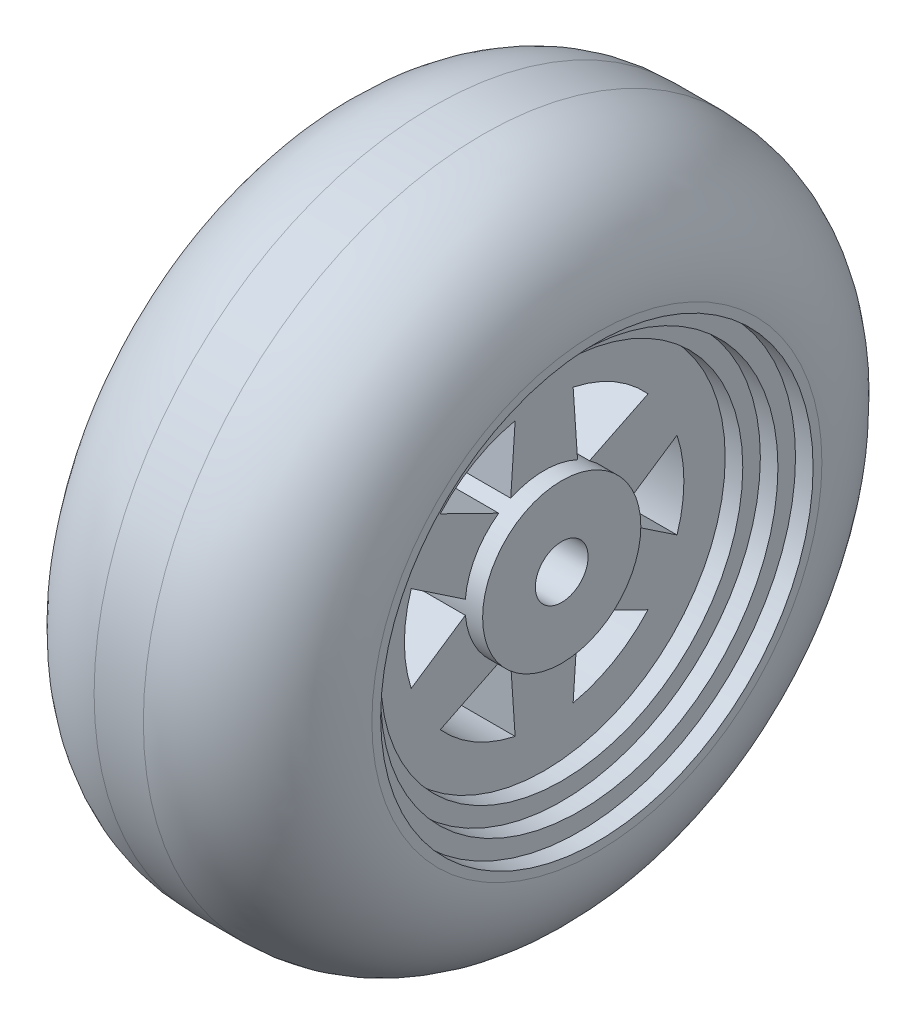
from build123d import *

# Parameters (mm, degrees)
ESQUISSE1_R             = 19.3
EXTRUSION1_DEPTH        = 15.8
ESQUISSE2_R             = 12.3
ENL_V_MAT_EXTRU_1_DEPTH = 1
ESQUISSE3_R             = 11.3
ENL_V_MAT_EXTRU_2_DEPTH = 1
ESQUISSE4_R             = 10.3
ENL_V_MAT_EXTRU_3_DEPTH = 1
ESQUISSE6_R             = 12.3
ENL_V_MAT_EXTRU_4_DEPTH = 1
ESQUISSE7_R             = 4.5
EXTRUSION3_DEPTH        = 5
ESQUISSE8_R             = 4.5
EXTRUSION4_DEPTH        = 1
ESQUISSE9_R             = 1.5
ENL_V_MAT_EXTRU_5_DEPTH = 18.8
CONG_1_R                = 6.5


with BuildPart() as part:
    # Esquisse1 → Extrusion1 (new body)
    with BuildSketch(Plane(origin=(0, 0, 0), x_dir=(0, 0, -1), z_dir=(1, 0, 0))):
        Circle(ESQUISSE1_R)
        with BuildLine():
            Line((1.9, 4.079215611), (1.65, 7.776888838))
            ThreePointArc((1.65, 7.776888838), (3.975, 6.88490196), (5.909983296, 5.317386335))
            Line((5.909983296, 5.317386335), (2.582704347, 3.685056073))
            ThreePointArc((2.582704347, 3.685056073), (2.25, 3.897114317), (1.9, 4.079215611))
        make_face(mode=Mode.SUBTRACT)
        with BuildLine():
            Line((-1.9, 4.079215611), (-1.65, 7.776888838))
            ThreePointArc((-1.65, 7.776888838), (-3.975, 6.88490196), (-5.909983296, 5.317386335))
            Line((-5.909983296, 5.317386335), (-2.582704347, 3.685056073))
            ThreePointArc((-2.582704347, 3.685056073), (-2.25, 3.897114317), (-1.9, 4.079215611))
        make_face(mode=Mode.SUBTRACT)
        with BuildLine():
            Line((4.482704347, 0.394159538), (7.559983296, 2.459502503))
            ThreePointArc((7.559983296, 2.459502503), (7.95, 0), (7.559983296, -2.459502503))
            Line((7.559983296, -2.459502503), (4.482704347, -0.394159538))
            ThreePointArc((4.482704347, -0.394159538), (4.5, 0), (4.482704347, 0.394159538))
        make_face(mode=Mode.SUBTRACT)
        with BuildLine():
            Line((2.582704347, -3.685056073), (5.909983296, -5.317386335))
            ThreePointArc((5.909983296, -5.317386335), (3.975, -6.88490196), (1.65, -7.776888838))
            Line((1.65, -7.776888838), (1.9, -4.079215611))
            ThreePointArc((1.9, -4.079215611), (2.25, -3.897114317), (2.582704347, -3.685056073))
        make_face(mode=Mode.SUBTRACT)
        with BuildLine():
            Line((-1.9, -4.079215611), (-1.65, -7.776888838))
            ThreePointArc((-1.65, -7.776888838), (-3.975, -6.88490196), (-5.909983296, -5.317386335))
            Line((-5.909983296, -5.317386335), (-2.582704347, -3.685056073))
            ThreePointArc((-2.582704347, -3.685056073), (-2.25, -3.897114317), (-1.9, -4.079215611))
        make_face(mode=Mode.SUBTRACT)
        with BuildLine():
            Line((-4.482704347, -0.394159538), (-7.559983296, -2.459502503))
            ThreePointArc((-7.559983296, -2.459502503), (-7.95, 0), (-7.559983296, 2.459502503))
            Line((-7.559983296, 2.459502503), (-4.482704347, 0.394159538))
            ThreePointArc((-4.482704347, 0.394159538), (-4.5, 0), (-4.482704347, -0.394159538))
        make_face(mode=Mode.SUBTRACT)
    extrude(amount=EXTRUSION1_DEPTH)

    # Esquisse2 → Enlèv. mat.-Extru.1 (cut)
    with BuildSketch(Plane(origin=(15.8, 0, 0), x_dir=(0, 0, -1), z_dir=(1, 0, 0))):
        Circle(ESQUISSE2_R)
    extrude(amount=-ENL_V_MAT_EXTRU_1_DEPTH, mode=Mode.SUBTRACT)

    # Esquisse3 → Enlèv. mat.-Extru.2 (cut)
    with BuildSketch(Plane(origin=(14.8, 0, 0), x_dir=(0, 0, -1), z_dir=(1, 0, 0))):
        Circle(ESQUISSE3_R)
    extrude(amount=-ENL_V_MAT_EXTRU_2_DEPTH, mode=Mode.SUBTRACT)

    # Esquisse4 → Enlèv. mat.-Extru.3 (cut)
    with BuildSketch(Plane(origin=(13.8, 0, 0), x_dir=(0, 0, -1), z_dir=(1, 0, 0))):
        Circle(ESQUISSE4_R)
    extrude(amount=-ENL_V_MAT_EXTRU_3_DEPTH, mode=Mode.SUBTRACT)

    # Esquisse6 → Enlèv. mat.-Extru.4 (cut)
    with BuildSketch(Plane.ZY):
        Circle(ESQUISSE6_R)
    extrude(amount=-ENL_V_MAT_EXTRU_4_DEPTH, mode=Mode.SUBTRACT)

    # Esquisse7 → Extrusion3 (add)
    with BuildSketch(Plane.ZY.offset(-1)):
        Circle(ESQUISSE7_R)
    extrude(amount=EXTRUSION3_DEPTH)

    # Esquisse8 → Extrusion4 (add)
    with BuildSketch(Plane(origin=(12.8, 0, 0), x_dir=(0, 0, -1), z_dir=(1, 0, 0))):
        Circle(ESQUISSE8_R)
    extrude(amount=EXTRUSION4_DEPTH)

    # Esquisse9 → Enlèv. mat.-Extru.5 (cut, through all)
    with BuildSketch(Plane(origin=(13.8, 0, 0), x_dir=(0, 0, -1), z_dir=(1, 0, 0))):
        Circle(ESQUISSE9_R)
    extrude(amount=-ENL_V_MAT_EXTRU_5_DEPTH, mode=Mode.SUBTRACT)

    # Congé1
    cong_1_edges = [part.edges().sort_by_distance(p)[0] for p in [
        (0, 0, 19.3),
        (15.8, 0, 19.3),
    ]]
    fillet(cong_1_edges, radius=CONG_1_R)


solid = part.part
